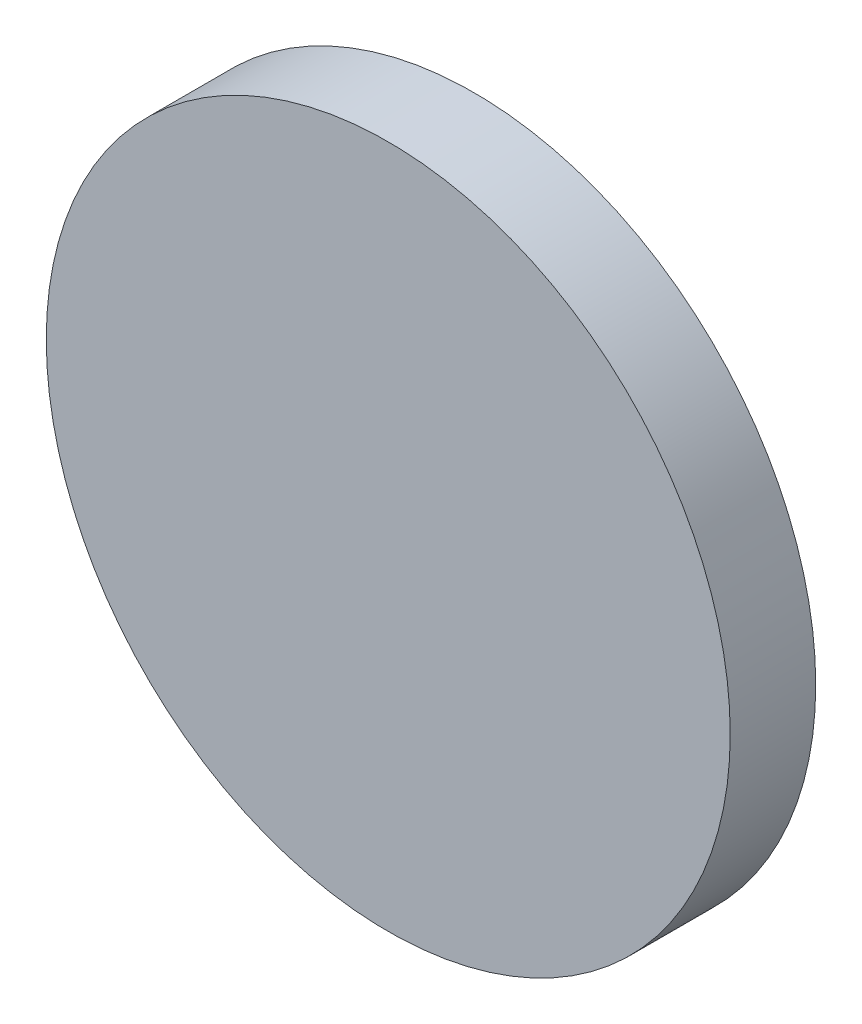
from build123d import *

# Parameters (mm, degrees)
SKETCH_1_R      = 4
EXTRUDE_1_DEPTH = 1


with BuildPart() as part:
    # 草图1 → 凸台-拉伸1 (new body)
    with BuildSketch(Plane.XY):
        Circle(SKETCH_1_R)
    extrude(amount=EXTRUDE_1_DEPTH)


solid = part.part
